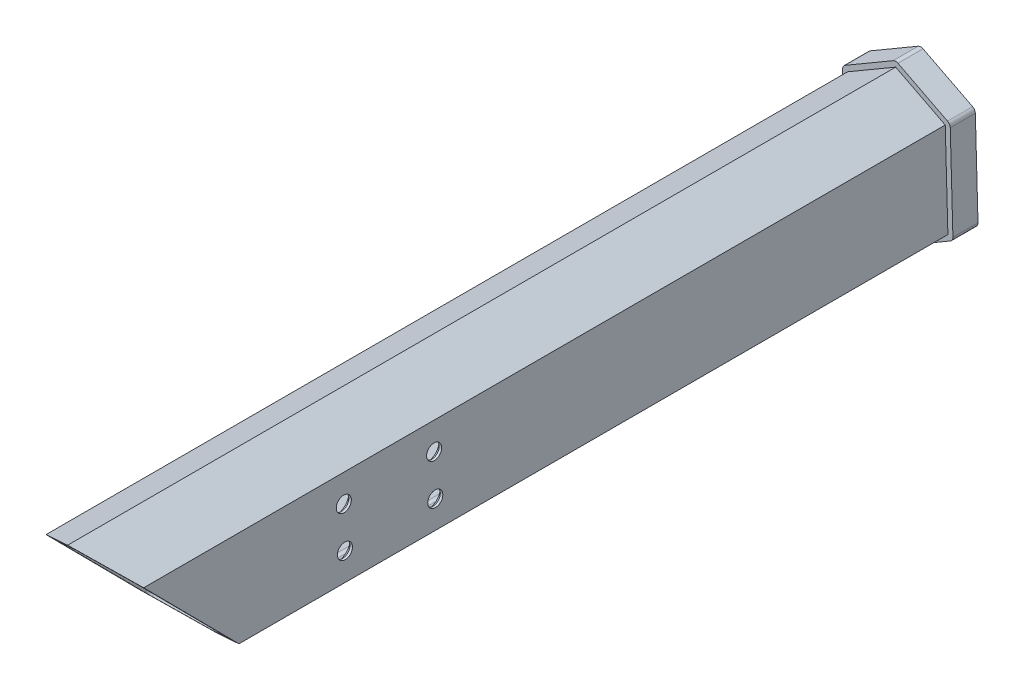
from build123d import *

# Parameters (mm, degrees)
BOSS_EXTRUDE1_DEPTH = 5
BOSS_EXTRUDE2_DEPTH = 165
SKETCH3_R           = 1.5
CUT_EXTRUDE1_DEPTH  = 165
SKETCH4_R           = 1.5
CUT_EXTRUDE2_DEPTH  = 3
CHAMFER1_SIZE       = 1


with BuildPart() as part:
    # Sketch1 → Boss-Extrude1 (new body)
    with BuildSketch(Plane.XY):
        with BuildLine():
            Line((269.472126518, 195.948380571), (259.892978717, 190.352443674))
            ThreePointArc((259.892978717, 190.352443674), (259.523120334, 189.974415309), (259.397797004, 189.460611133))
            Line((259.397797004, 189.460611133), (259.926827069, 170.821662041))
            ThreePointArc((259.926827069, 170.821662041), (260.081091813, 170.315793424), (260.471796679, 169.959352158))
            Line((260.471796679, 169.959352158), (270.352926754, 164.915757134))
            ThreePointArc((270.352926754, 164.915757134), (270.835926205, 164.806841188), (271.311970321, 164.942977708))
            Line((271.311970321, 164.942977708), (280.891118122, 170.538914605))
            ThreePointArc((280.891118122, 170.538914605), (281.260976505, 170.916942969), (281.386299835, 171.430747146))
            Line((281.386299835, 171.430747146), (280.85726977, 190.069696238))
            ThreePointArc((280.85726977, 190.069696238), (280.703005026, 190.575564854), (280.31230016, 190.93200612))
            Line((280.31230016, 190.93200612), (270.431170085, 195.975601144))
            ThreePointArc((270.431170085, 195.975601144), (269.948170634, 196.08451709), (269.472126518, 195.948380571))
        make_face()
        with BuildLine():
            Line((269.536796739, 193.669899558), (262.417863464, 189.511168301))
            ThreePointArc((262.417863464, 189.511168301), (262.048005081, 189.133139936), (261.922681752, 188.61933576))
            Line((261.922681752, 188.61933576), (262.399929545, 171.804795492))
            ThreePointArc((262.399929545, 171.804795492), (262.554194289, 171.298926876), (262.944899155, 170.942485609))
            Line((262.944899155, 170.942485609), (270.288256533, 167.194238147))
            ThreePointArc((270.288256533, 167.194238147), (270.771255984, 167.085322201), (271.2473001, 167.22145872))
            Line((271.2473001, 167.22145872), (278.366233375, 171.380189978))
            ThreePointArc((278.366233375, 171.380189978), (278.736091758, 171.758218342), (278.861415087, 172.272022518))
            Line((278.861415087, 172.272022518), (278.384167294, 189.086562786))
            ThreePointArc((278.384167294, 189.086562786), (278.22990255, 189.592431403), (277.839197684, 189.948872669))
            Line((277.839197684, 189.948872669), (270.495840306, 193.697120131))
            ThreePointArc((270.495840306, 193.697120131), (270.012840855, 193.806036078), (269.536796739, 193.669899558))
        make_face(mode=Mode.SUBTRACT)
    extrude(amount=BOSS_EXTRUDE1_DEPTH)

    # Sketch2 → Boss-Extrude2 (add)
    with BuildSketch(Plane.XY.offset(5)):
        Polygon((279.857672325, 190.041324622), (269.97654225, 195.084919646), (260.397394449, 189.488982749), (260.926424514, 170.850033657), (270.807554589, 165.806438633), (280.38670239, 171.40237553), align=None)
        with BuildLine():
            Line((269.536796739, 193.669899558), (262.417863464, 189.511168301))
            ThreePointArc((262.417863464, 189.511168301), (262.048005081, 189.133139936), (261.922681752, 188.61933576))
            Line((261.922681752, 188.61933576), (262.399929545, 171.804795492))
            ThreePointArc((262.399929545, 171.804795492), (262.554194289, 171.298926876), (262.944899155, 170.942485609))
            Line((262.944899155, 170.942485609), (270.288256533, 167.194238147))
            ThreePointArc((270.288256533, 167.194238147), (270.771255984, 167.085322201), (271.2473001, 167.22145872))
            Line((271.2473001, 167.22145872), (278.366233375, 171.380189978))
            ThreePointArc((278.366233375, 171.380189978), (278.736091758, 171.758218342), (278.861415087, 172.272022518))
            Line((278.861415087, 172.272022518), (278.384167294, 189.086562786))
            ThreePointArc((278.384167294, 189.086562786), (278.22990255, 189.592431403), (277.839197684, 189.948872669))
            Line((277.839197684, 189.948872669), (270.495840306, 193.697120131))
            ThreePointArc((270.495840306, 193.697120131), (270.012840855, 193.806036078), (269.536796739, 193.669899558))
        make_face(mode=Mode.SUBTRACT)
    extrude(amount=BOSS_EXTRUDE2_DEPTH)

    # Sketch3 → Cut-Extrude1 (cut)
    with BuildSketch(Plane(origin=(265.561732352, 7.537449653, 0), x_dir=(0, 0, 1), z_dir=(-0.999597445, -0.028371616, 0))):
        with Locations((107, 176.701580488)):
            Circle(SKETCH3_R)
        with Locations((107, 168.701580488)):
            Circle(SKETCH3_R)
        with Locations((125, 176.701580488)):
            Circle(SKETCH3_R)
        with Locations((125, 168.701580488)):
            Circle(SKETCH3_R)
        Polygon((170, 187.346716472), (170, 158.056444505), (141, 158.056444505), align=None)
    extrude(amount=-CUT_EXTRUDE1_DEPTH, mode=Mode.SUBTRACT)

    # Sketch4 → Cut-Extrude2 (cut)
    with BuildSketch(Plane(origin=(265.561732352, 7.537449653, 0), x_dir=(0, 0, 1), z_dir=(-0.999597445, -0.028371616, 0))):
        with Locations((15, 172.701580488)):
            Circle(SKETCH4_R)
    extrude(amount=-CUT_EXTRUDE2_DEPTH, mode=Mode.SUBTRACT)

    # Chamfer1
    chamfer1_edges = [part.edges().sort_by_distance(p)[0] for p in [
        (262.274792111, 176.213675847, 105.5),
        (278.736277653, 176.680902874, 105.5),
        (262.047819186, 184.210455405, 123.5),
        (278.509304728, 184.677682431, 123.5),
        (262.274792111, 176.213675847, 123.5),
        (278.736277653, 176.680902874, 123.5),
        (262.047819186, 184.210455405, 105.5),
        (278.509304728, 184.677682431, 105.5),
        (262.161305648, 180.212065626, 13.5),
    ]]
    chamfer(chamfer1_edges, length=CHAMFER1_SIZE)


solid = part.part
